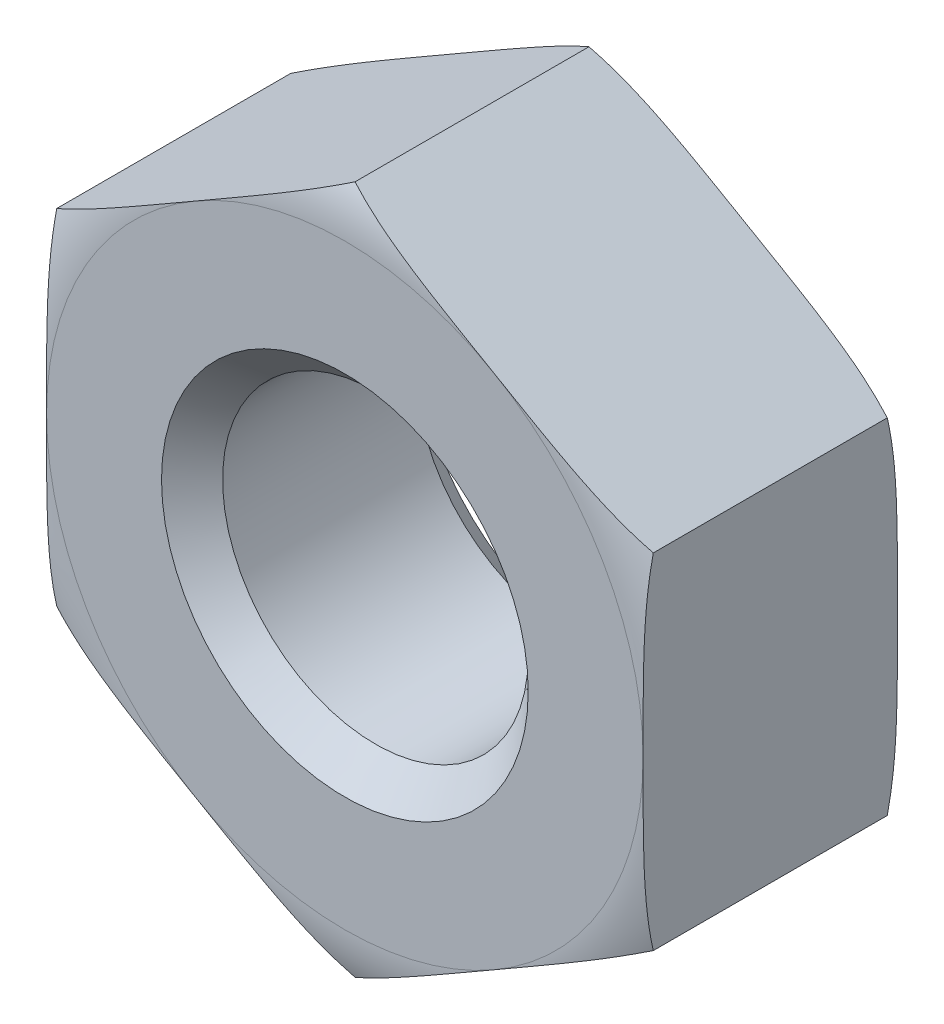
from build123d import *

# Parameters (mm, degrees)
SKETCH1_R           = 1.25
BOSS_EXTRUDE1_DEPTH = 2.08
CHAMFER1_SIZE       = 0.25


with BuildPart() as part:
    # Sketch1 → Boss-Extrude1 (new body)
    with BuildSketch(Plane.XY):
        Polygon((2.44, 1.408734657), (0, 2.817469314), (-2.44, 1.408734657), (-2.44, -1.408734657), (0, -2.817469314), (2.44, -1.408734657), align=None)
        Circle(SKETCH1_R, mode=Mode.SUBTRACT)
    extrude(amount=BOSS_EXTRUDE1_DEPTH)

    # Chamfer1
    chamfer1_edges = [part.edges().sort_by_distance(p)[0] for p in [
        (-1.25, 0, 0),
        (-1.25, 0, 2.08),
    ]]
    chamfer(chamfer1_edges, length=CHAMFER1_SIZE)

    # Sketch2 → Cut-Revolve1 (revolve, cut)
    with BuildSketch(Plane(origin=(0, 0, 0), x_dir=(1, 0, 0), z_dir=(0, 1, 0))):
        with BuildLine():
            Line((-3.307835601, -0.663581472), (-4.500819954, -0.663581472))
            Line((-4.500819954, -0.663581472), (-4.500819954, 0.361239255))
            Line((-4.500819954, 0.361239255), (-2.44, 0.361239255))
            Line((-2.44, 0.361239255), (-2.44, 0))
            ThreePointArc((-2.44, 0), (-2.986232322, -0.184905169), (-3.307835601, -0.663581472))
        make_face()
        with BuildLine():
            Line((-2.44, -2.441239255), (-2.44, -2.08))
            ThreePointArc((-2.44, -2.08), (-2.986232322, -1.895094831), (-3.307835601, -1.416418528))
            Line((-3.307835601, -1.416418528), (-4.500819954, -1.416418528))
            Line((-4.500819954, -1.416418528), (-4.500819954, -2.441239255))
            Line((-4.500819954, -2.441239255), (-2.44, -2.441239255))
        make_face()
    revolve(axis=Axis((0, 0, 1.04), (0, 0, -1)), mode=Mode.SUBTRACT)


solid = part.part
